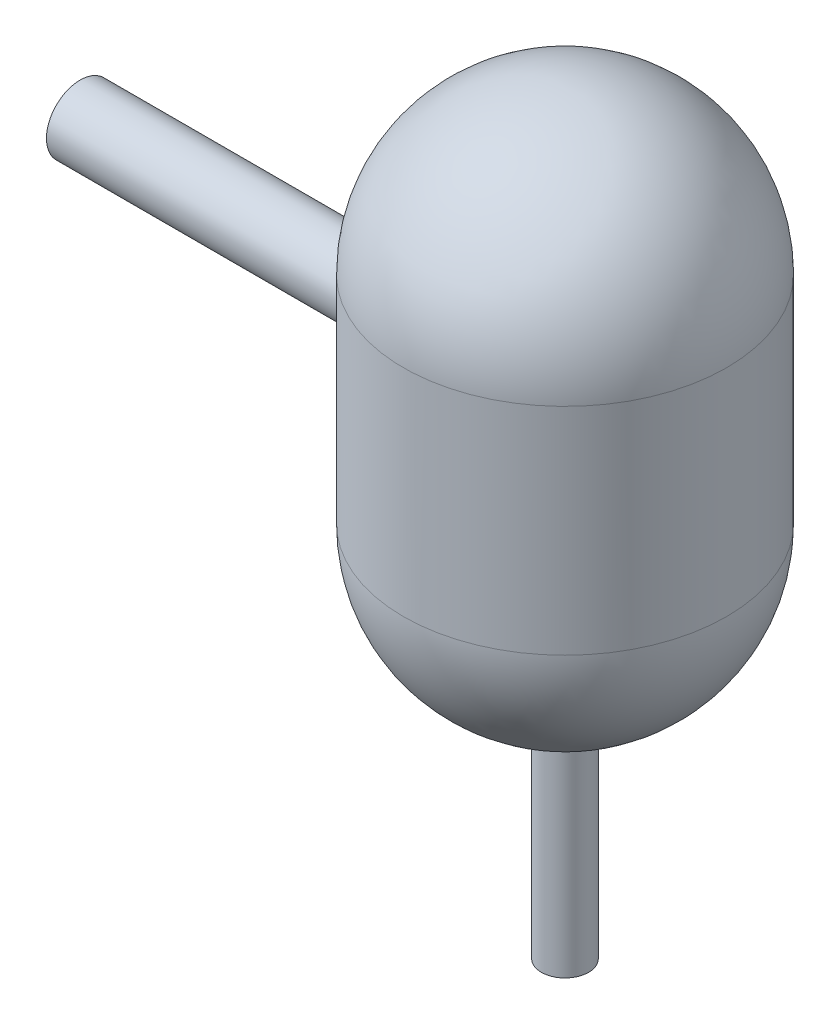
from build123d import *

# Parameters (mm, degrees)
CUT_EXTRUDE1_REACH       = 154.4
CUT_EXTRUDE1_END_RADIUS  = 152.4
SKETCH2_R                = 25.4
BOSS_EXTRUDE3_REACH      = 611.6
BOSS_EXTRUDE3_END_RADIUS = 152.4
SKETCH4_R                = 31.75
SKETCH4_R_2              = 25.4
CUT_EXTRUDE2_REACH       = 713.2
CUT_EXTRUDE2_END_RADIUS  = 146.05
SKETCH5_R                = 15.875
BOSS_EXTRUDE4_REACH      = 713.2
BOSS_EXTRUDE4_END_RADIUS = 152.4
SKETCH6_R                = 22.225
SKETCH6_R_2              = 15.875


with BuildPart() as part:
    # Sketch1 → Revolve1 (revolve)
    with BuildSketch(Plane.XY, mode=Mode.PRIVATE) as revolve1_sk:
        with BuildLine():
            Line((-152.4, 101.6), (-152.4, -101.6))
            ThreePointArc((-152.4, -101.6), (-107.763073453, -209.363073453), (0, -254))
            Line((0, -254), (0, -247.65))
            ThreePointArc((0, -247.65), (-103.272945392, -204.872945392), (-146.05, -101.6))
            Line((-146.05, -101.6), (-146.05, 101.6))
            ThreePointArc((-146.05, 101.6), (-103.272945392, 204.872945392), (0, 247.65))
            Line((0, 247.65), (0, 254))
            ThreePointArc((0, 254), (-107.763073453, 209.363073453), (-152.4, 101.6))
        make_face()
    revolve(revolve1_sk.sketch.rotate(Axis((0, -254, 0), (0, 1, 0)), 180), axis=Axis((0, -254, 0), (0, 1, 0)))  # turned: the seam where the file's is

    # Cut-Extrude1: up to this cylinder (the profile starts inside it)
    cut_extrude1_end = Plane(origin=(0, 0, 0), z_dir=(0, -1, 0)) * Cylinder(CUT_EXTRUDE1_END_RADIUS, 614.6, mode=Mode.PRIVATE)
    # Sketch2 → Cut-Extrude1 (cut, up to the surface)
    with BuildSketch(Plane(origin=(0, 0, 0), x_dir=(0, 0, -1), z_dir=(1, 0, 0)), mode=Mode.PRIVATE) as cut_extrude1_sk1:
        Circle(SKETCH2_R)
    cut_extrude1_tool1 = extrude(cut_extrude1_sk1.sketch, amount=-CUT_EXTRUDE1_REACH, mode=Mode.PRIVATE) & cut_extrude1_end
    add(cut_extrude1_tool1.solids().sort_by_distance((0, 0, 0))[0], mode=Mode.SUBTRACT)

    # Boss-Extrude3: up to this cylinder (the profile starts outside it)
    boss_extrude3_end = Plane(origin=(0, 0, 0), z_dir=(0, -1, 0)) * Cylinder(BOSS_EXTRUDE3_END_RADIUS, 1529, mode=Mode.PRIVATE)
    # Sketch4 → Boss-Extrude3 (add, up to the surface)
    with BuildSketch(Plane(origin=(-457.2, 0, 0), x_dir=(0, 0, -1), z_dir=(1, 0, 0)), mode=Mode.PRIVATE) as boss_extrude3_sk1:
        with Locations(Location((0, 0, 0), (0, 0, 180))):  # turned: the seam where the file's is
            Circle(SKETCH4_R)
        Circle(SKETCH4_R_2, mode=Mode.SUBTRACT)
    boss_extrude3_tool1 = extrude(boss_extrude3_sk1.sketch, amount=BOSS_EXTRUDE3_REACH, mode=Mode.PRIVATE) - boss_extrude3_end
    add(boss_extrude3_tool1.solids().sort_by_distance((-457.2, 0, -30.851974))[0])

    # Cut-Extrude2: up to this sphere (the profile starts outside it)
    cut_extrude2_end = Location((0, -101.6, 0)) * Sphere(CUT_EXTRUDE2_END_RADIUS, mode=Mode.PRIVATE)
    # Sketch5 → Cut-Extrude2 (cut, up to the surface)
    with BuildSketch(Plane(origin=(0, -457.2, 0), x_dir=(1, 0, 0), z_dir=(0, 1, 0)), mode=Mode.PRIVATE) as cut_extrude2_sk1:
        with Locations(Location((0, 0, 0), (0, 0, 270))):  # turned: the seam where the file's is
            Circle(SKETCH5_R)
    cut_extrude2_tool1 = extrude(cut_extrude2_sk1.sketch, amount=CUT_EXTRUDE2_REACH, mode=Mode.PRIVATE) - cut_extrude2_end
    add(cut_extrude2_tool1.solids().sort_by_distance((0, -457.2, 0))[0], mode=Mode.SUBTRACT)

    # Boss-Extrude4: up to this sphere (the profile starts outside it)
    boss_extrude4_end = Location((0, -101.6, 0)) * Sphere(BOSS_EXTRUDE4_END_RADIUS, mode=Mode.PRIVATE)
    # Sketch6 → Boss-Extrude4 (add, up to the surface)
    with BuildSketch(Plane(origin=(0, -457.2, 0), x_dir=(1, 0, 0), z_dir=(0, 1, 0)), mode=Mode.PRIVATE) as boss_extrude4_sk1:
        with Locations(Location((0, 0, 0), (0, 0, 270))):  # turned: the seam where the file's is
            Circle(SKETCH6_R)
        with Locations(Location((0, 0, 0), (0, 0, 270))):  # turned: the seam where the file's is
            Circle(SKETCH6_R_2, mode=Mode.SUBTRACT)
    boss_extrude4_tool1 = extrude(boss_extrude4_sk1.sketch, amount=BOSS_EXTRUDE4_REACH, mode=Mode.PRIVATE) - boss_extrude4_end
    add(boss_extrude4_tool1.solids().sort_by_distance((0, -457.2, -21.596382))[0])


solid = part.part
